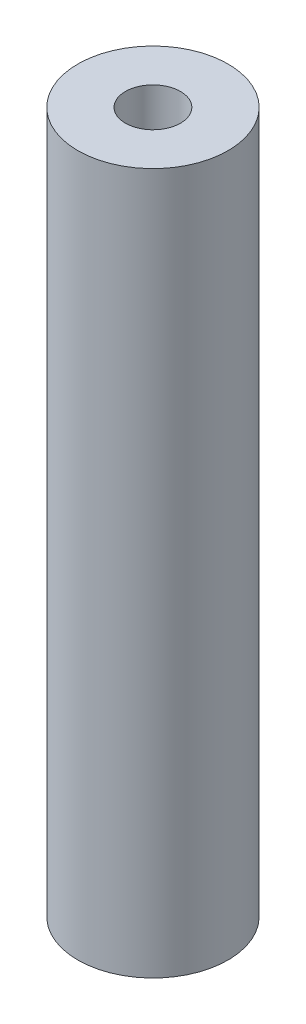
from build123d import *

# Parameters (mm, degrees)
SKETCH1_R           = 7.5
SKETCH1_R_2         = 2.75
BOSS_EXTRUDE1_DEPTH = 70


with BuildPart() as part:
    # Sketch1 → Boss-Extrude1 (new body)
    with BuildSketch(Plane(origin=(0, 952.688222755, 0), x_dir=(1, 0, 0), z_dir=(0, 1, 0))):
        with Locations((738.258051733, -1161.214475077)):
            Circle(SKETCH1_R)
        with Locations((738.258051733, -1161.214475077)):
            Circle(SKETCH1_R_2, mode=Mode.SUBTRACT)
    extrude(amount=BOSS_EXTRUDE1_DEPTH)


solid = part.part
